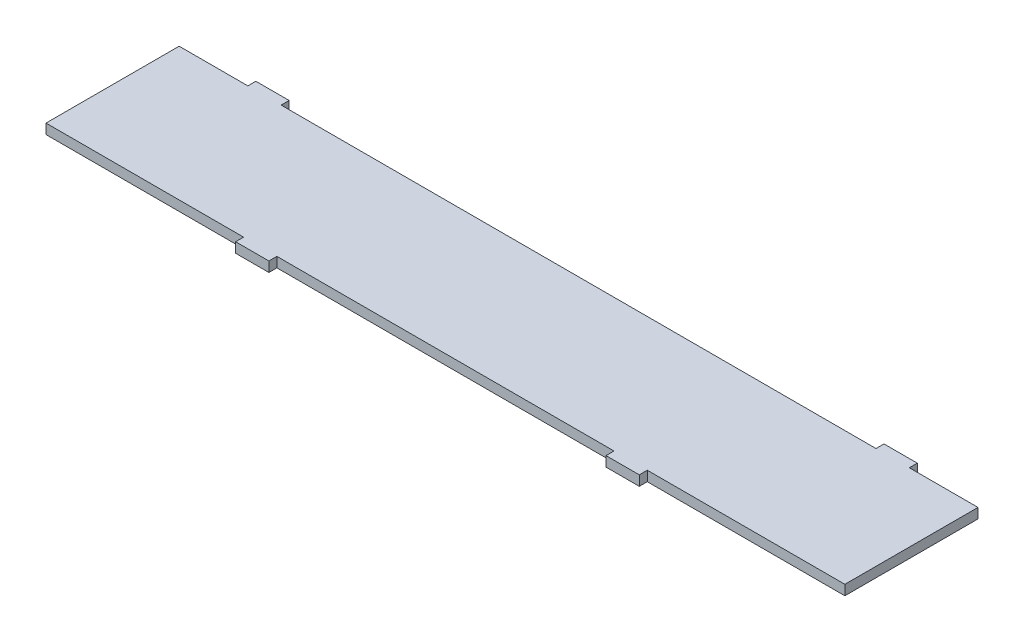
from build123d import *

# Parameters (mm, degrees)
CROQUIS1_W              = 1200
CROQUIS1_H              = 200
SALIENTE_EXTRUIR1_DEPTH = 15
CROQUIS3_W              = 50
CROQUIS3_H              = 12
SALIENTE_EXTRUIR2_DEPTH = 15


with BuildPart() as part:
    # Croquis1 → Saliente-Extruir1 (new body)
    with BuildSketch(Plane(origin=(0, 0, 0), x_dir=(1, 0, 0), z_dir=(0, 1, 0))):
        Rectangle(CROQUIS1_W, CROQUIS1_H)
    extrude(amount=SALIENTE_EXTRUIR1_DEPTH)

    # Croquis3 → Saliente-Extruir2 (add)
    with BuildSketch(Plane(origin=(0, 0, 0), x_dir=(1, 0, 0), z_dir=(0, 1, 0))):
        with Locations((471.8, 106)):
            Rectangle(CROQUIS3_W, CROQUIS3_H)
        with Locations((-471.8, 106)):
            Rectangle(CROQUIS3_W, CROQUIS3_H)
        with Locations((-278.2, -106)):
            Rectangle(CROQUIS3_W, CROQUIS3_H)
        with Locations((278.2, -106)):
            Rectangle(CROQUIS3_W, CROQUIS3_H)
    extrude(amount=SALIENTE_EXTRUIR2_DEPTH)


solid = part.part
